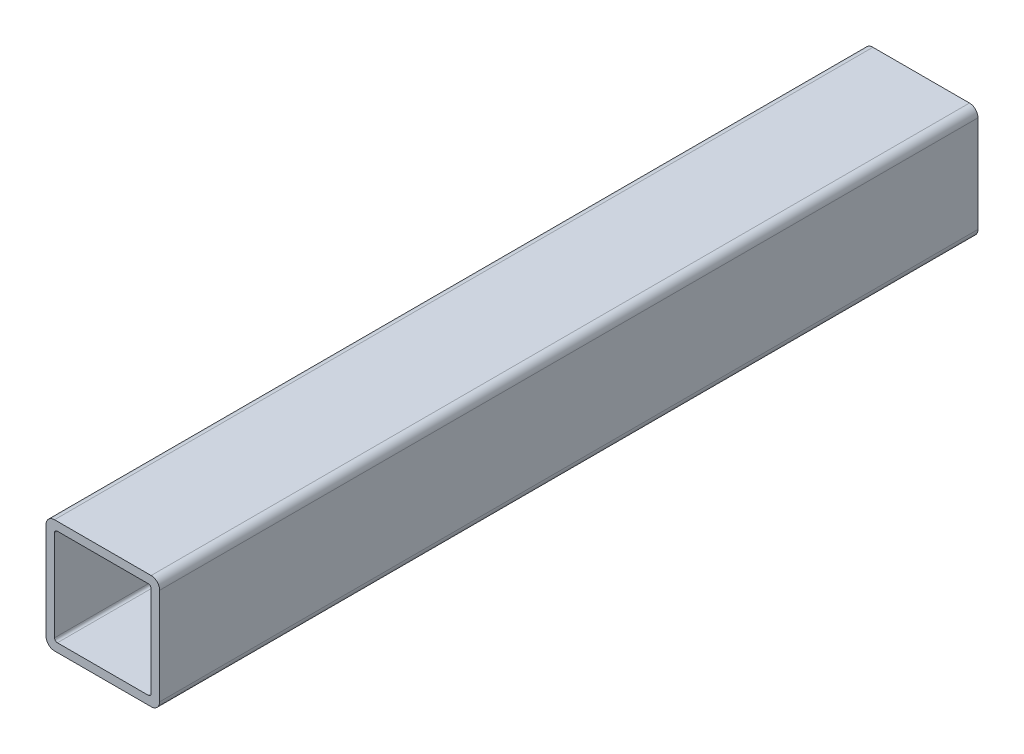
from build123d import *

# Parameters (mm, degrees)
BOSS_EXTRUDE1_DEPTH = 228.6


with BuildPart() as part:
    # Sketch1 → Boss-Extrude1 (new body, symmetric)
    with BuildSketch(Plane.XY):
        with BuildLine():
            Line((-26.9875, 31.75), (26.9875, 31.75))
            ThreePointArc((26.9875, 31.75), (30.355096045, 30.355096045), (31.75, 26.9875))
            Line((31.75, 26.9875), (31.75, -26.9875))
            ThreePointArc((31.75, -26.9875), (30.355096045, -30.355096045), (26.9875, -31.75))
            Line((26.9875, -31.75), (-26.9875, -31.75))
            ThreePointArc((-26.9875, -31.75), (-30.355096045, -30.355096045), (-31.75, -26.9875))
            Line((-31.75, -26.9875), (-31.75, 26.9875))
            ThreePointArc((-31.75, 26.9875), (-30.355096045, 30.355096045), (-26.9875, 31.75))
        make_face()
        with BuildLine():
            Line((-25.4, 26.9875), (25.4, 26.9875))
            ThreePointArc((25.4, 26.9875), (26.522532015, 26.522532015), (26.9875, 25.4))
            Line((26.9875, 25.4), (26.9875, -25.4))
            ThreePointArc((26.9875, -25.4), (26.522532015, -26.522532015), (25.4, -26.9875))
            Line((25.4, -26.9875), (-25.4, -26.9875))
            ThreePointArc((-25.4, -26.9875), (-26.522532015, -26.522532015), (-26.9875, -25.4))
            Line((-26.9875, -25.4), (-26.9875, 25.4))
            ThreePointArc((-26.9875, 25.4), (-26.522532015, 26.522532015), (-25.4, 26.9875))
        make_face(mode=Mode.SUBTRACT)
    extrude(amount=BOSS_EXTRUDE1_DEPTH, both=True)


solid = part.part
